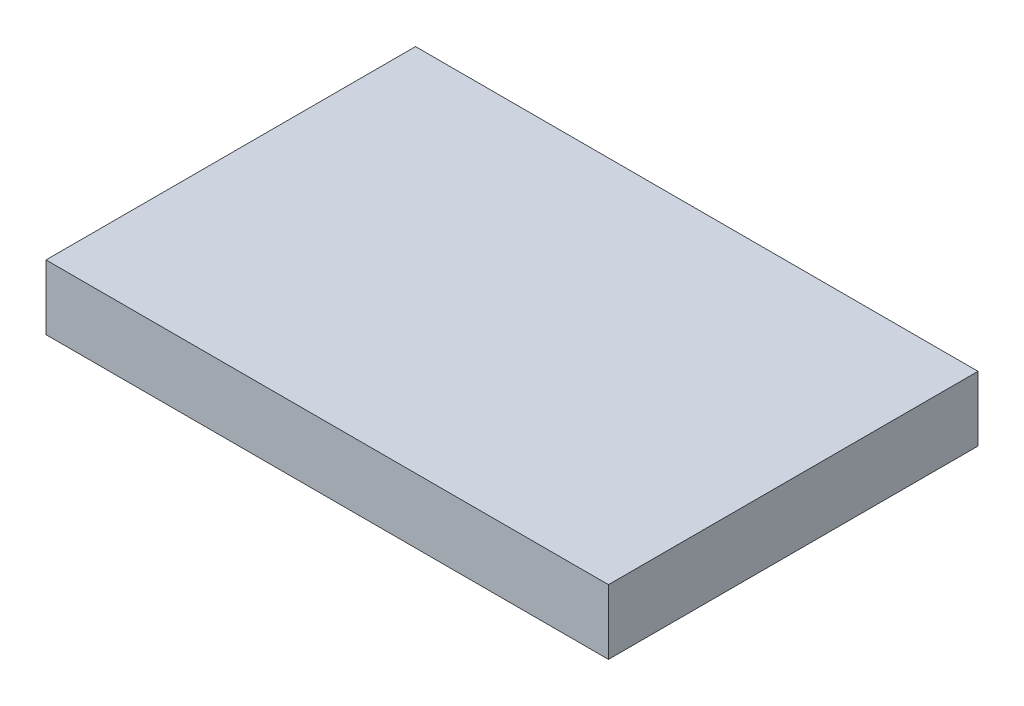
from build123d import *

# Parameters (mm, degrees)
SKETCH1_W           = 86
SKETCH1_H           = 56.5
BOSS_EXTRUDE1_DEPTH = 9.9


with BuildPart() as part:
    # Sketch1 → Boss-Extrude1 (new body)
    with BuildSketch(Plane(origin=(0, 0, 0), x_dir=(1, 0, 0), z_dir=(0, 1, 0))):
        with Locations((43, 28.25)):
            Rectangle(SKETCH1_W, SKETCH1_H)
    extrude(amount=BOSS_EXTRUDE1_DEPTH)


solid = part.part
